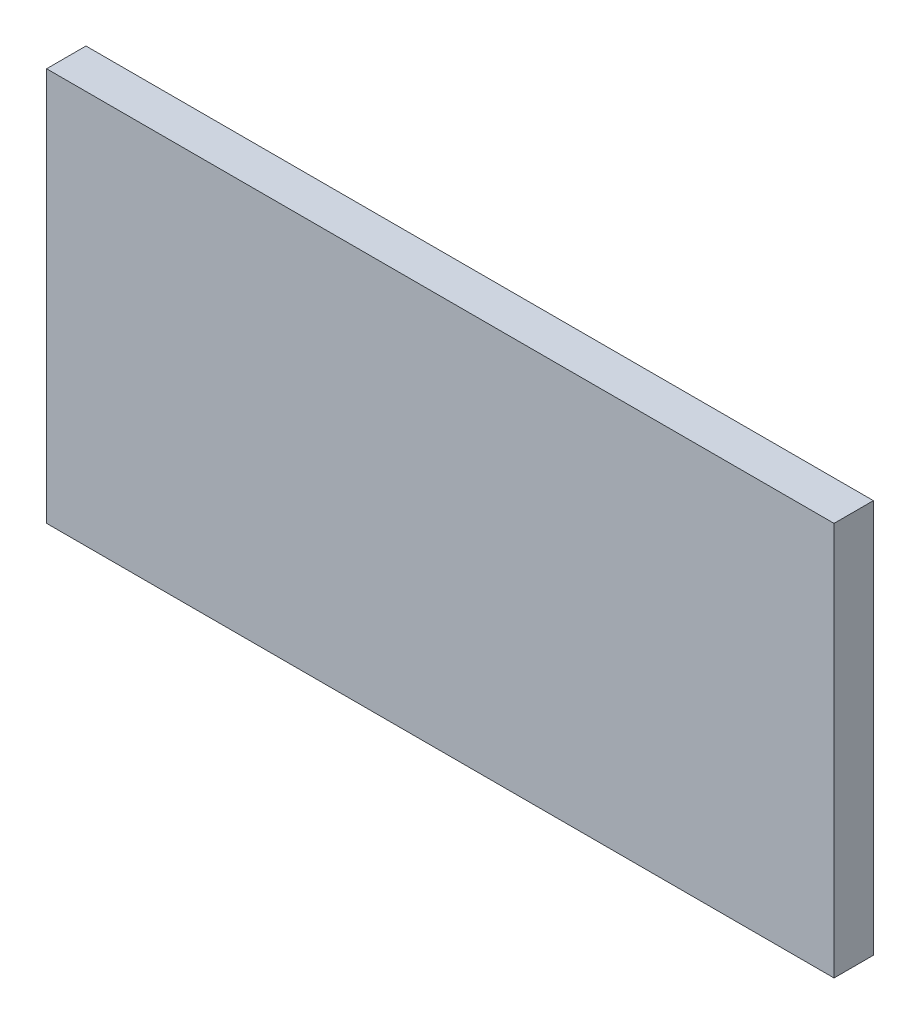
from build123d import *

# Parameters (mm, degrees)
SKETCH_1_W      = 60
SKETCH_1_H      = 30
EXTRUDE_1_DEPTH = 3


with BuildPart() as part:
    # 草图1 → 凸台-拉伸1 (new body)
    with BuildSketch(Plane.XY):
        Rectangle(SKETCH_1_W, SKETCH_1_H)
    extrude(amount=EXTRUDE_1_DEPTH)


solid = part.part
